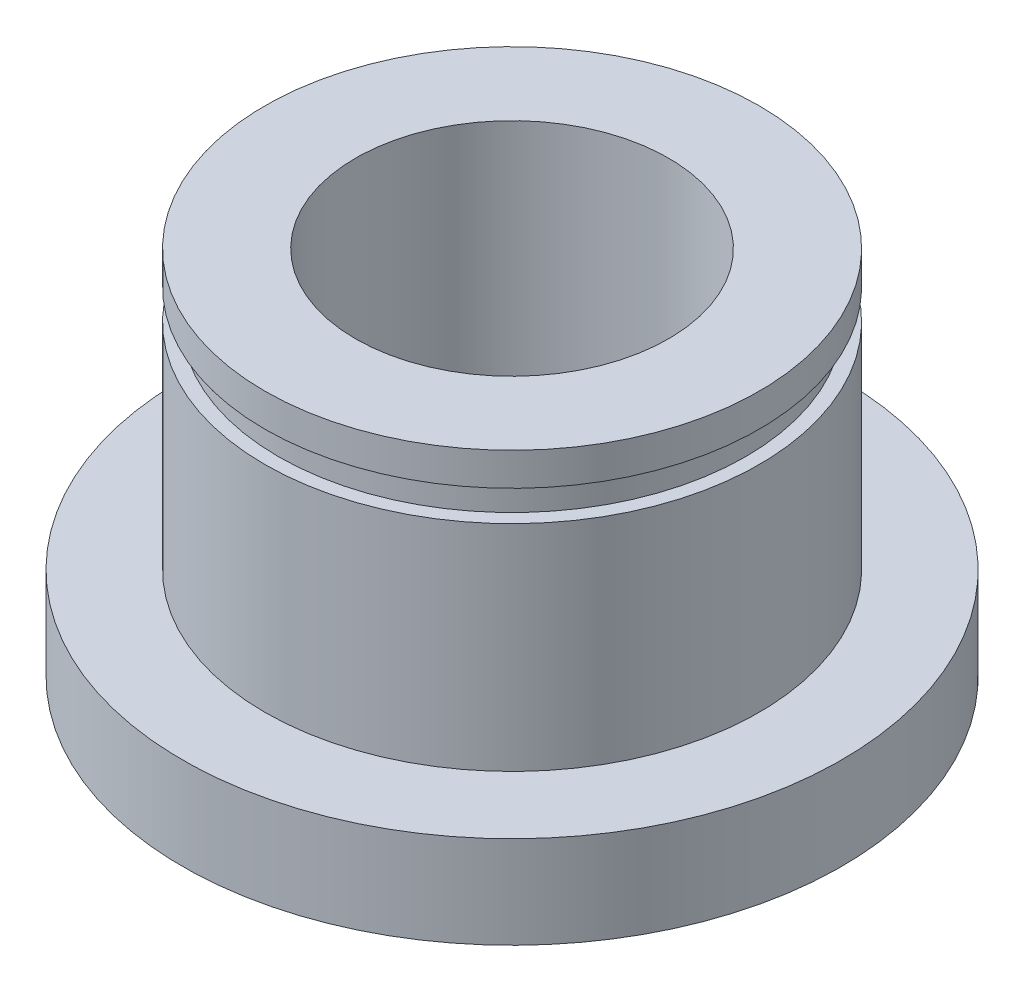
from build123d import *

# Parameters (mm, degrees)
F_19_64_0_29688_DIAMETER_HOLE1_D = 7.540752
CHAMFER1_SIZE                    = 0.79375


with BuildPart() as part:
    # Sketch1 → Revolve1 (revolve)
    with BuildSketch(Plane(origin=(0, 0, 0), x_dir=(0, 0, -1), z_dir=(1, 0, 0))):
        Polygon((0, -4.460875), (-7.9375, -4.460875), (-7.9375, -2.238375), (-5.953125, -2.238375), (-5.953125, 2.930525), (-5.6261, 2.930525), (-5.6261, 3.667125), (-5.953125, 3.667125), (-5.953125, 4.460875), (0, 4.460875), align=None)
    revolve(axis=Axis((0, 0, 0), (0, 1, 0)))

    # 19/64 (0.29688) Diameter Hole1 (through all)
    with Locations(Plane(origin=(0, 4.460875, 0), x_dir=(1, 0, 0), z_dir=(0, 1, 0))):
        with Locations((0, 0)):
            Hole(F_19_64_0_29688_DIAMETER_HOLE1_D / 2)

    # Chamfer1
    chamfer1_edges = [part.edges().sort_by_distance(p)[0] for p in [
        (3.770376, -4.460875, 0),
    ]]
    chamfer(chamfer1_edges, length=CHAMFER1_SIZE)


solid = part.part
